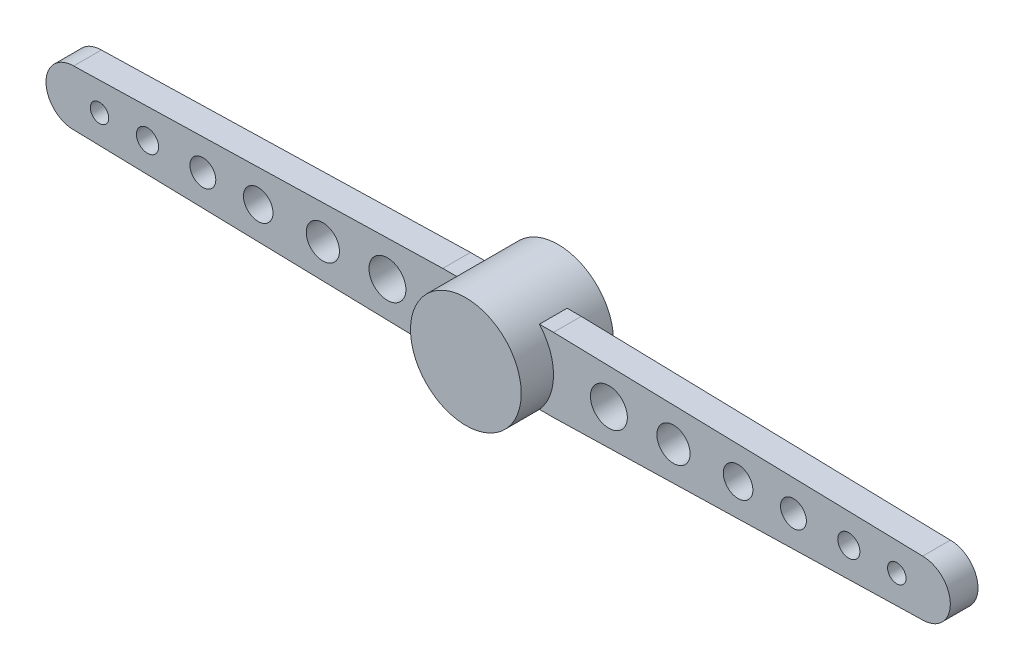
from build123d import *

# Parameters (mm, degrees)
SKETCH1_R                  = 1.5
BOSS_EXTRUDE1_DEPTH        = 2.5
SKETCH1_3_R                = 1
CUT_EXTRUDE1_DEPTH         = 2
BOSS_EXTRUDE2_DEPTH        = 0.375
BOSS_EXTRUDE2_DEPTH_BACK   = 0.375
BOSS_EXTRUDE2_2_DEPTH      = 0.375
BOSS_EXTRUDE2_2_DEPTH_BACK = 0.375
BOSS_EXTRUDE3_START        = -0.381966
SKETCH2_W                  = 0.75
SKETCH2_H                  = 2
BOSS_EXTRUDE3_DEPTH        = 0.381966
SKETCH4_W                  = 0.75
SKETCH4_H                  = 2
BOSS_EXTRUDE4_DEPTH        = 0.381966
CUT_EXTRUDE2_REACH         = 3.625
SKETCH5_R                  = 0.25
SKETCH5_R_2                = 0.3
SKETCH5_R_3                = 0.35
SKETCH5_R_4                = 0.4
SKETCH5_R_5                = 0.45
SKETCH5_R_6                = 0.5


with BuildPart() as part:
    # Sketch1 → Boss-Extrude1 (new body)
    with BuildSketch(Plane.XY):
        Circle(SKETCH1_R)
    extrude(amount=BOSS_EXTRUDE1_DEPTH)

    # Sketch1_3 → Cut-Extrude1 (cut)
    with BuildSketch(Plane.XY):
        Circle(SKETCH1_3_R)
    extrude(amount=CUT_EXTRUDE1_DEPTH, mode=Mode.SUBTRACT)



with BuildPart() as body_2:
    # Sketch3 → Boss-Extrude2 (new body, two sides)
    with BuildSketch(Plane(origin=(0, 0, 1.25), x_dir=(0, -1, 0), z_dir=(0, 0, -1))) as boss_extrude2_sk:
        with BuildLine():
            Line((1, 1.5), (0.75, 11.5))
            ThreePointArc((0.75, 11.5), (0, 12.25), (-0.75, 11.5))
            Line((-0.75, 11.5), (-1, 1.5))
            Line((-1, 1.5), (1, 1.5))
        make_face()
    extrude(amount=BOSS_EXTRUDE2_DEPTH)
    extrude(boss_extrude2_sk.sketch, amount=-BOSS_EXTRUDE2_DEPTH_BACK)


with BuildPart() as body_3:
    # Sketch3 → Boss-Extrude2 2 (new body, two sides)
    with BuildSketch(Plane(origin=(0, 0, 1.25), x_dir=(0, -1, 0), z_dir=(0, 0, -1))) as boss_extrude2_2_sk:
        with BuildLine():
            Line((-1, -1.5), (-0.75, -11.5))
            ThreePointArc((-0.75, -11.5), (0, -12.25), (0.75, -11.5))
            Line((0.75, -11.5), (1, -1.5))
            Line((1, -1.5), (-1, -1.5))
        make_face()
    extrude(amount=BOSS_EXTRUDE2_2_DEPTH)
    extrude(boss_extrude2_2_sk.sketch, amount=-BOSS_EXTRUDE2_2_DEPTH_BACK)


with BuildPart() as part_1:
    add(part.part)

    add(body_2.part)  # Boss-Extrude3 merges body 2
    # Sketch2 → Boss-Extrude3 (add)
    with BuildSketch(Plane.ZY.offset(1.5).offset(BOSS_EXTRUDE3_START)):
        with Locations((1.25, 0)):
            Rectangle(SKETCH2_W, SKETCH2_H)
    extrude(amount=BOSS_EXTRUDE3_DEPTH)


    add(body_3.part)  # Boss-Extrude4 merges body 3
    # Sketch4 → Boss-Extrude4 (add)
    with BuildSketch(Plane.ZY.offset(-1.5)):
        with Locations((1.25, 0)):
            Rectangle(SKETCH4_W, SKETCH4_H)
    extrude(amount=BOSS_EXTRUDE4_DEPTH)

    # Sketch5 → Cut-Extrude2 (cut, up to next)
    with BuildSketch(Plane.XY.offset(1.625), mode=Mode.PRIVATE) as cut_extrude2_sk1:
        with Locations((-10.8, 0)):
            Circle(SKETCH5_R)
    cut_extrude2_tool1 = extrude(cut_extrude2_sk1.sketch, amount=-CUT_EXTRUDE2_REACH, mode=Mode.PRIVATE) & part_1.part
    add(cut_extrude2_tool1.solids().sort_by_distance((-10.8, 0, 1.625))[0], mode=Mode.SUBTRACT)
    # Sketch5 → Cut-Extrude2 (cut, up to next)
    with BuildSketch(Plane.XY.offset(1.625), mode=Mode.PRIVATE) as cut_extrude2_sk2:
        with Locations((-9.5, 0)):
            Circle(SKETCH5_R_2)
    cut_extrude2_tool2 = extrude(cut_extrude2_sk2.sketch, amount=-CUT_EXTRUDE2_REACH, mode=Mode.PRIVATE) & part_1.part
    add(cut_extrude2_tool2.solids().sort_by_distance((-9.5, 0, 1.625))[0], mode=Mode.SUBTRACT)
    # Sketch5 → Cut-Extrude2 (cut, up to next)
    with BuildSketch(Plane.XY.offset(1.625), mode=Mode.PRIVATE) as cut_extrude2_sk3:
        with Locations((-8, 0)):
            Circle(SKETCH5_R_3)
    cut_extrude2_tool3 = extrude(cut_extrude2_sk3.sketch, amount=-CUT_EXTRUDE2_REACH, mode=Mode.PRIVATE) & part_1.part
    add(cut_extrude2_tool3.solids().sort_by_distance((-8, 0, 1.625))[0], mode=Mode.SUBTRACT)
    # Sketch5 → Cut-Extrude2 (cut, up to next)
    with BuildSketch(Plane.XY.offset(1.625), mode=Mode.PRIVATE) as cut_extrude2_sk4:
        with Locations((-6.5, 0)):
            Circle(SKETCH5_R_4)
    cut_extrude2_tool4 = extrude(cut_extrude2_sk4.sketch, amount=-CUT_EXTRUDE2_REACH, mode=Mode.PRIVATE) & part_1.part
    add(cut_extrude2_tool4.solids().sort_by_distance((-6.5, 0, 1.625))[0], mode=Mode.SUBTRACT)
    # Sketch5 → Cut-Extrude2 (cut, up to next)
    with BuildSketch(Plane.XY.offset(1.625), mode=Mode.PRIVATE) as cut_extrude2_sk5:
        with Locations((-4.75, 0)):
            Circle(SKETCH5_R_5)
    cut_extrude2_tool5 = extrude(cut_extrude2_sk5.sketch, amount=-CUT_EXTRUDE2_REACH, mode=Mode.PRIVATE) & part_1.part
    add(cut_extrude2_tool5.solids().sort_by_distance((-4.75, 0, 1.625))[0], mode=Mode.SUBTRACT)
    # Sketch5 → Cut-Extrude2 (cut, up to next)
    with BuildSketch(Plane.XY.offset(1.625), mode=Mode.PRIVATE) as cut_extrude2_sk6:
        with Locations((-3, 0)):
            Circle(SKETCH5_R_6)
    cut_extrude2_tool6 = extrude(cut_extrude2_sk6.sketch, amount=-CUT_EXTRUDE2_REACH, mode=Mode.PRIVATE) & part_1.part
    add(cut_extrude2_tool6.solids().sort_by_distance((-3, 0, 1.625))[0], mode=Mode.SUBTRACT)
    # Sketch5 → Cut-Extrude2 (cut, up to next)
    with BuildSketch(Plane.XY.offset(1.625), mode=Mode.PRIVATE) as cut_extrude2_sk7:
        with Locations((3, 0)):
            Circle(SKETCH5_R_6)
    cut_extrude2_tool7 = extrude(cut_extrude2_sk7.sketch, amount=-CUT_EXTRUDE2_REACH, mode=Mode.PRIVATE) & part_1.part
    add(cut_extrude2_tool7.solids().sort_by_distance((3, 0, 1.625))[0], mode=Mode.SUBTRACT)
    # Sketch5 → Cut-Extrude2 (cut, up to next)
    with BuildSketch(Plane.XY.offset(1.625), mode=Mode.PRIVATE) as cut_extrude2_sk8:
        with Locations((4.75, 0)):
            Circle(SKETCH5_R_5)
    cut_extrude2_tool8 = extrude(cut_extrude2_sk8.sketch, amount=-CUT_EXTRUDE2_REACH, mode=Mode.PRIVATE) & part_1.part
    add(cut_extrude2_tool8.solids().sort_by_distance((4.75, 0, 1.625))[0], mode=Mode.SUBTRACT)
    # Sketch5 → Cut-Extrude2 (cut, up to next)
    with BuildSketch(Plane.XY.offset(1.625), mode=Mode.PRIVATE) as cut_extrude2_sk9:
        with Locations((6.5, 0)):
            Circle(SKETCH5_R_4)
    cut_extrude2_tool9 = extrude(cut_extrude2_sk9.sketch, amount=-CUT_EXTRUDE2_REACH, mode=Mode.PRIVATE) & part_1.part
    add(cut_extrude2_tool9.solids().sort_by_distance((6.5, 0, 1.625))[0], mode=Mode.SUBTRACT)
    # Sketch5 → Cut-Extrude2 (cut, up to next)
    with BuildSketch(Plane.XY.offset(1.625), mode=Mode.PRIVATE) as cut_extrude2_sk10:
        with Locations((8, 0)):
            Circle(SKETCH5_R_3)
    cut_extrude2_tool10 = extrude(cut_extrude2_sk10.sketch, amount=-CUT_EXTRUDE2_REACH, mode=Mode.PRIVATE) & part_1.part
    add(cut_extrude2_tool10.solids().sort_by_distance((8, 0, 1.625))[0], mode=Mode.SUBTRACT)
    # Sketch5 → Cut-Extrude2 (cut, up to next)
    with BuildSketch(Plane.XY.offset(1.625), mode=Mode.PRIVATE) as cut_extrude2_sk11:
        with Locations((9.5, 0)):
            Circle(SKETCH5_R_2)
    cut_extrude2_tool11 = extrude(cut_extrude2_sk11.sketch, amount=-CUT_EXTRUDE2_REACH, mode=Mode.PRIVATE) & part_1.part
    add(cut_extrude2_tool11.solids().sort_by_distance((9.5, 0, 1.625))[0], mode=Mode.SUBTRACT)
    # Sketch5 → Cut-Extrude2 (cut, up to next)
    with BuildSketch(Plane.XY.offset(1.625), mode=Mode.PRIVATE) as cut_extrude2_sk12:
        with Locations((10.8, 0)):
            Circle(SKETCH5_R)
    cut_extrude2_tool12 = extrude(cut_extrude2_sk12.sketch, amount=-CUT_EXTRUDE2_REACH, mode=Mode.PRIVATE) & part_1.part
    add(cut_extrude2_tool12.solids().sort_by_distance((10.8, 0, 1.625))[0], mode=Mode.SUBTRACT)


solid = part_1.part
